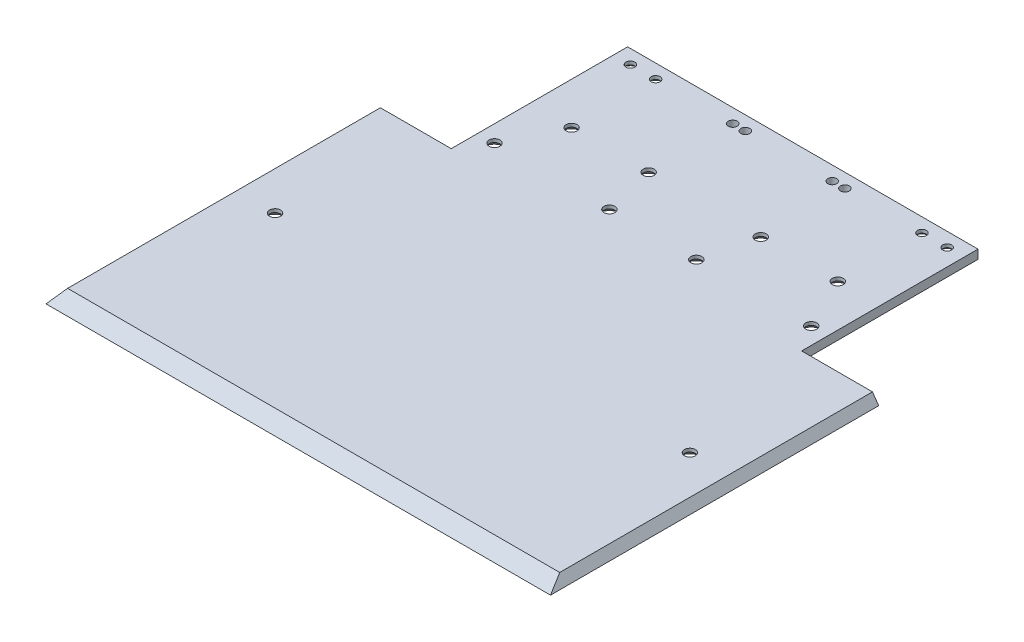
from build123d import *

# Parameters (mm, degrees)
SALIENTE_EXTRUIR1_DEPTH                      = 3.17
CORTAR_EXTRUIR1_REACH                        = 182
CORTAR_EXTRUIR7_START                        = -117.08
CORTAR_EXTRUIR7_DEPTH                        = 117.08
CROQUIS3_R                                   = 1.585
CORTAR_EXTRUIR2_DEPTH                        = 3.17
CORTAR_EXTRUIR3_REACH                        = 5.17
CROQUIS4_R                                   = 1.585
CORTAR_EXTRUIR4_REACH                        = 5.17
CROQUIS6_R                                   = 1.585
CROQUIS7_R                                   = 1.585
CORTAR_EXTRUIR5_DEPTH                        = 3.17
CROQUIS15_R                                  = 4
CORTAR_EXTRUIR6_DEPTH                        = 2
CORTAR_EXTRUIR6_TAPER                        = 50.5
AVELLANADO_PARA_TORNILLO_CON_CABEZA_2_COUNT  = 2
AVELLANADO_PARA_TORNILLO_CON_CABEZA_2_PITCH  = 63.24912037
AVELLANADO_PARA_TORNILLO_CON_CABEZA_3_COUNT  = 2
AVELLANADO_PARA_TORNILLO_CON_CABEZA_3_PITCH  = 83.591620659
AVELLANADO_PARA_TORNILLO_CON_CABEZA_4_COUNT  = 2
AVELLANADO_PARA_TORNILLO_CON_CABEZA_4_PITCH  = 95.923454089
AVELLANADO_PARA_TORNILLO_CON_CABEZA_5_COUNT  = 2
AVELLANADO_PARA_TORNILLO_CON_CABEZA_5_PITCH  = 84.359061325
AVELLANADO_PARA_TORNILLO_CON_CABEZA_6_COUNT  = 2
AVELLANADO_PARA_TORNILLO_CON_CABEZA_6_PITCH  = 108.187112114
AVELLANADO_PARA_TORNILLO_CON_CABEZA_7_COUNT  = 2
AVELLANADO_PARA_TORNILLO_CON_CABEZA_7_PITCH  = 122.968731979
AVELLANADO_PARA_TORNILLO_CON_CABEZA_8_COUNT  = 2
AVELLANADO_PARA_TORNILLO_CON_CABEZA_8_PITCH  = 145.077768953
AVELLANADO_PARA_TORNILLO_CON_CABEZA_9_COUNT  = 2
AVELLANADO_PARA_TORNILLO_CON_CABEZA_9_PITCH  = 143.959894511
AVELLANADO_PARA_TORNILLO_CON_CABEZA_10_COUNT = 2
AVELLANADO_PARA_TORNILLO_CON_CABEZA_10_PITCH = 148


with BuildPart() as part:
    # Croquis1 → Saliente-Extruir1 (new body)
    with BuildSketch(Plane(origin=(0, 0, 0), x_dir=(1, 0, 0), z_dir=(0, 1, 0))):
        Polygon((-62.5, 90), (-62.5, 27.08), (-90, 27.08), (-90, -90), (90, -90), (90, 27.08), (62.5, 27.08), (62.5, 90), align=None)
    extrude(amount=SALIENTE_EXTRUIR1_DEPTH)

    # Croquis2 → Cortar-Extruir1 (cut, up to next)
    with BuildSketch(Plane.ZY.offset(90), mode=Mode.PRIVATE) as cortar_extruir1_sk1:
        Polygon((90, 0), (84.50939894, 3.17), (90, 3.17), align=None)
    cortar_extruir1_tool1 = extrude(cortar_extruir1_sk1.sketch, amount=-CORTAR_EXTRUIR1_REACH, mode=Mode.PRIVATE) & part.part
    add(cortar_extruir1_tool1.solids().sort_by_distance((-90, 2.113333, 88.1698))[0], mode=Mode.SUBTRACT)

    # Croquis16 → Cortar-Extruir7 (cut)
    with BuildSketch(Plane(origin=(0, 0, -27.08), x_dir=(-1, 0, 0), z_dir=(0, 0, -1)).offset(CORTAR_EXTRUIR7_START)):
        Polygon((90, 3.17), (90, 0), (87.780342104, 3.17), align=None)
    cortar_extruir7 = extrude(amount=CORTAR_EXTRUIR7_DEPTH, mode=Mode.SUBTRACT)

    # Simetría4: Cortar-Extruir7 across plane
    add(cortar_extruir7.mirror(Plane(origin=(0, 0, 0), x_dir=(0, 0, 1), z_dir=(1, 0, 0))), mode=Mode.SUBTRACT)

    # Croquis3 → Cortar-Extruir2 (cut)
    with BuildSketch(Plane(origin=(0, 3.17, 0), x_dir=(1, 0, 0), z_dir=(0, 1, 0))):
        with Locations((74, -24.279339937)):
            Circle(CROQUIS3_R)
    cortar_extruir2 = extrude(amount=-CORTAR_EXTRUIR2_DEPTH, mode=Mode.SUBTRACT)

    # Simetría1: Cortar-Extruir2 across plane
    add(cortar_extruir2.mirror(Plane(origin=(0, 0, 0), x_dir=(0, 0, 1), z_dir=(1, 0, 0))), mode=Mode.SUBTRACT)

    # Croquis4 → Cortar-Extruir3 (cut, up to next)
    with BuildSketch(Plane(origin=(0, 3.17, 0), x_dir=(1, 0, 0), z_dir=(0, 1, 0)), mode=Mode.PRIVATE) as cortar_extruir3_sk1:
        with Locations((-56.5, 36.50060106)):
            Circle(CROQUIS4_R)
    cortar_extruir3_tool1 = extrude(cortar_extruir3_sk1.sketch, amount=-CORTAR_EXTRUIR3_REACH, mode=Mode.PRIVATE) & part.part
    add(cortar_extruir3_tool1.solids().sort_by_distance((-56.5, 3.17, -36.500601))[0], mode=Mode.SUBTRACT)
    # Croquis4 → Cortar-Extruir3 (cut, up to next)
    with BuildSketch(Plane(origin=(0, 3.17, 0), x_dir=(1, 0, 0), z_dir=(0, 1, 0)), mode=Mode.PRIVATE) as cortar_extruir3_sk2:
        with Locations((-15.5, 36.50060106)):
            Circle(CROQUIS4_R)
    cortar_extruir3_tool2 = extrude(cortar_extruir3_sk2.sketch, amount=-CORTAR_EXTRUIR3_REACH, mode=Mode.PRIVATE) & part.part
    add(cortar_extruir3_tool2.solids().sort_by_distance((-15.5, 3.17, -36.500601))[0], mode=Mode.SUBTRACT)
    # Croquis4 → Cortar-Extruir3 (cut, up to next)
    with BuildSketch(Plane(origin=(0, 3.17, 0), x_dir=(1, 0, 0), z_dir=(0, 1, 0)), mode=Mode.PRIVATE) as cortar_extruir3_sk3:
        with Locations((-15.5, 85.00060106)):
            Circle(CROQUIS4_R)
    cortar_extruir3_tool3 = extrude(cortar_extruir3_sk3.sketch, amount=-CORTAR_EXTRUIR3_REACH, mode=Mode.PRIVATE) & part.part
    add(cortar_extruir3_tool3.solids().sort_by_distance((-15.5, 3.17, -85.000601))[0], mode=Mode.SUBTRACT)
    # Croquis4 → Cortar-Extruir3 (cut, up to next)
    with BuildSketch(Plane(origin=(0, 3.17, 0), x_dir=(1, 0, 0), z_dir=(0, 1, 0)), mode=Mode.PRIVATE) as cortar_extruir3_sk4:
        with Locations((-56.5, 85.00060106)):
            Circle(CROQUIS4_R)
    cortar_extruir3_tool4 = extrude(cortar_extruir3_sk4.sketch, amount=-CORTAR_EXTRUIR3_REACH, mode=Mode.PRIVATE) & part.part
    add(cortar_extruir3_tool4.solids().sort_by_distance((-56.5, 3.17, -85.000601))[0], mode=Mode.SUBTRACT)

    # Croquis6 → Cortar-Extruir4 (cut, up to next)
    with BuildSketch(Plane(origin=(0, 3.17, 0), x_dir=(1, 0, 0), z_dir=(0, 1, 0)), mode=Mode.PRIVATE) as cortar_extruir4_sk1:
        with Locations((56.5, 85.00060106)):
            Circle(CROQUIS6_R)
    cortar_extruir4_tool1 = extrude(cortar_extruir4_sk1.sketch, amount=-CORTAR_EXTRUIR4_REACH, mode=Mode.PRIVATE) & part.part
    add(cortar_extruir4_tool1.solids().sort_by_distance((56.5, 3.17, -85.000601))[0], mode=Mode.SUBTRACT)
    # Croquis6 → Cortar-Extruir4 (cut, up to next)
    with BuildSketch(Plane(origin=(0, 3.17, 0), x_dir=(1, 0, 0), z_dir=(0, 1, 0)), mode=Mode.PRIVATE) as cortar_extruir4_sk2:
        with Locations((15.5, 85.00060106)):
            Circle(CROQUIS6_R)
    cortar_extruir4_tool2 = extrude(cortar_extruir4_sk2.sketch, amount=-CORTAR_EXTRUIR4_REACH, mode=Mode.PRIVATE) & part.part
    add(cortar_extruir4_tool2.solids().sort_by_distance((15.5, 3.17, -85.000601))[0], mode=Mode.SUBTRACT)
    # Croquis6 → Cortar-Extruir4 (cut, up to next)
    with BuildSketch(Plane(origin=(0, 3.17, 0), x_dir=(1, 0, 0), z_dir=(0, 1, 0)), mode=Mode.PRIVATE) as cortar_extruir4_sk3:
        with Locations((15.5, 36.50060106)):
            Circle(CROQUIS6_R)
    cortar_extruir4_tool3 = extrude(cortar_extruir4_sk3.sketch, amount=-CORTAR_EXTRUIR4_REACH, mode=Mode.PRIVATE) & part.part
    add(cortar_extruir4_tool3.solids().sort_by_distance((15.5, 3.17, -36.500601))[0], mode=Mode.SUBTRACT)
    # Croquis6 → Cortar-Extruir4 (cut, up to next)
    with BuildSketch(Plane(origin=(0, 3.17, 0), x_dir=(1, 0, 0), z_dir=(0, 1, 0)), mode=Mode.PRIVATE) as cortar_extruir4_sk4:
        with Locations((56.5, 36.50060106)):
            Circle(CROQUIS6_R)
    cortar_extruir4_tool4 = extrude(cortar_extruir4_sk4.sketch, amount=-CORTAR_EXTRUIR4_REACH, mode=Mode.PRIVATE) & part.part
    add(cortar_extruir4_tool4.solids().sort_by_distance((56.5, 3.17, -36.500601))[0], mode=Mode.SUBTRACT)

    # Croquis7 → Cortar-Extruir5 (cut)
    with BuildSketch(Plane(origin=(0, 3.17, 0), x_dir=(1, 0, 0), z_dir=(0, 1, 0))):
        with Locations((-20, 85.00060106)):
            Circle(CROQUIS7_R)
        with Locations((-47.5, 85.00060106)):
            Circle(CROQUIS7_R)
        with Locations((-47.5, 55.00060106)):
            Circle(CROQUIS7_R)
        with Locations((-20, 55.00060106)):
            Circle(CROQUIS7_R)
    cortar_extruir5 = extrude(amount=-CORTAR_EXTRUIR5_DEPTH, mode=Mode.SUBTRACT)

    # Simetría2: Cortar-Extruir5 across plane
    add(cortar_extruir5.mirror(Plane(origin=(0, 0, 0), x_dir=(0, 0, 1), z_dir=(1, 0, 0))), mode=Mode.SUBTRACT)

    # Croquis15 → Cortar-Extruir6 (cut)
    with BuildSketch(Plane(origin=(0, 0, 0), x_dir=(-1, 0, 0), z_dir=(0, -1, 0))):
        with Locations((20, 55.00060106)):
            Circle(CROQUIS15_R)
        with Locations((15.5, 36.50060106)):
            Circle(CROQUIS15_R)
        with Locations((56.5, 36.50060106)):
            Circle(CROQUIS15_R)
        with Locations((47.5, 55.00060106)):
            Circle(CROQUIS15_R)
        with Locations((56.5, 85.00060106)):
            Circle(CROQUIS15_R)
        with Locations((47.5, 85.00060106)):
            Circle(CROQUIS15_R)
        with Locations((74, -24.279339937)):
            Circle(CROQUIS15_R)
    cortar_extruir6 = extrude(amount=-CORTAR_EXTRUIR6_DEPTH, taper=CORTAR_EXTRUIR6_TAPER, mode=Mode.SUBTRACT)

    # Simetría3: Cortar-Extruir6 across plane
    add(cortar_extruir6.mirror(Plane(origin=(0, 0, 0), x_dir=(0, 0, 1), z_dir=(1, 0, 0))), mode=Mode.SUBTRACT)

    # Croquis14 → Avellanado para tornillo con cabeza avellanada en cruz de M3.51 (revolve, cut)
    with BuildSketch(Plane(origin=(74, 0, 24.279339937), x_dir=(0, 0, -1), z_dir=(1, 0, 0))):
        Polygon((0, 0), (0, 3.17), (1.95, 3.17), (1.95, 1.979661988), (4, 0), align=None)
    avellanado_para_tornillo_con_cabeza_avel = revolve(axis=Axis((74, -6.35, 24.279339937), (0, 1, 0)), mode=Mode.SUBTRACT)

    # Avellanado para tornillo con cabeza  2: Avellanado para tornillo con cabeza avellanada en cruz de M3.51 ×2
    with Locations(*[Vector(-0.27668369, 0, -0.960961048) * (i * AVELLANADO_PARA_TORNILLO_CON_CABEZA_2_PITCH) for i in range(1, AVELLANADO_PARA_TORNILLO_CON_CABEZA_2_COUNT)]):
        add(avellanado_para_tornillo_con_cabeza_avel, mode=Mode.SUBTRACT)

    # Avellanado para tornillo con cabeza  3: Avellanado para tornillo con cabeza avellanada en cruz de M3.51 ×2
    with Locations(*[Vector(-0.317017421, 0, -0.948419714) * (i * AVELLANADO_PARA_TORNILLO_CON_CABEZA_3_PITCH) for i in range(1, AVELLANADO_PARA_TORNILLO_CON_CABEZA_3_COUNT)]):
        add(avellanado_para_tornillo_con_cabeza_avel, mode=Mode.SUBTRACT)

    # Avellanado para tornillo con cabeza  4: Avellanado para tornillo con cabeza avellanada en cruz de M3.51 ×2
    with Locations(*[Vector(-0.562948869, 0, -0.826491725) * (i * AVELLANADO_PARA_TORNILLO_CON_CABEZA_4_PITCH) for i in range(1, AVELLANADO_PARA_TORNILLO_CON_CABEZA_4_COUNT)]):
        add(avellanado_para_tornillo_con_cabeza_avel, mode=Mode.SUBTRACT)

    # Avellanado para tornillo con cabeza  5: Avellanado para tornillo con cabeza avellanada en cruz de M3.51 ×2
    with Locations(*[Vector(-0.693464331, 0, -0.720490959) * (i * AVELLANADO_PARA_TORNILLO_CON_CABEZA_5_PITCH) for i in range(1, AVELLANADO_PARA_TORNILLO_CON_CABEZA_5_COUNT)]):
        add(avellanado_para_tornillo_con_cabeza_avel, mode=Mode.SUBTRACT)

    # Avellanado para tornillo con cabeza  6: Avellanado para tornillo con cabeza avellanada en cruz de M3.51 ×2
    with Locations(*[Vector(-0.827270441, 0, -0.561803895) * (i * AVELLANADO_PARA_TORNILLO_CON_CABEZA_6_PITCH) for i in range(1, AVELLANADO_PARA_TORNILLO_CON_CABEZA_6_COUNT)]):
        add(avellanado_para_tornillo_con_cabeza_avel, mode=Mode.SUBTRACT)

    # Avellanado para tornillo con cabeza  7: Avellanado para tornillo con cabeza avellanada en cruz de M3.51 ×2
    with Locations(*[Vector(-0.764421967, 0, -0.64471626) * (i * AVELLANADO_PARA_TORNILLO_CON_CABEZA_7_PITCH) for i in range(1, AVELLANADO_PARA_TORNILLO_CON_CABEZA_7_COUNT)]):
        add(avellanado_para_tornillo_con_cabeza_avel, mode=Mode.SUBTRACT)

    # Avellanado para tornillo con cabeza  8: Avellanado para tornillo con cabeza avellanada en cruz de M3.51 ×2
    with Locations(*[Vector(-0.837481861, 0, -0.546465124) * (i * AVELLANADO_PARA_TORNILLO_CON_CABEZA_8_PITCH) for i in range(1, AVELLANADO_PARA_TORNILLO_CON_CABEZA_8_COUNT)]):
        add(avellanado_para_tornillo_con_cabeza_avel, mode=Mode.SUBTRACT)

    # Avellanado para tornillo con cabeza  9: Avellanado para tornillo con cabeza avellanada en cruz de M3.51 ×2
    with Locations(*[Vector(-0.90650247, 0, -0.422200511) * (i * AVELLANADO_PARA_TORNILLO_CON_CABEZA_9_PITCH) for i in range(1, AVELLANADO_PARA_TORNILLO_CON_CABEZA_9_COUNT)]):
        add(avellanado_para_tornillo_con_cabeza_avel, mode=Mode.SUBTRACT)

    # Avellanado para tornillo con cabeza  10: Avellanado para tornillo con cabeza avellanada en cruz de M3.51 ×2
    with Locations(*[(-i * AVELLANADO_PARA_TORNILLO_CON_CABEZA_10_PITCH, 0, 0) for i in range(1, AVELLANADO_PARA_TORNILLO_CON_CABEZA_10_COUNT)]):
        add(avellanado_para_tornillo_con_cabeza_avel, mode=Mode.SUBTRACT)


solid = part.part
